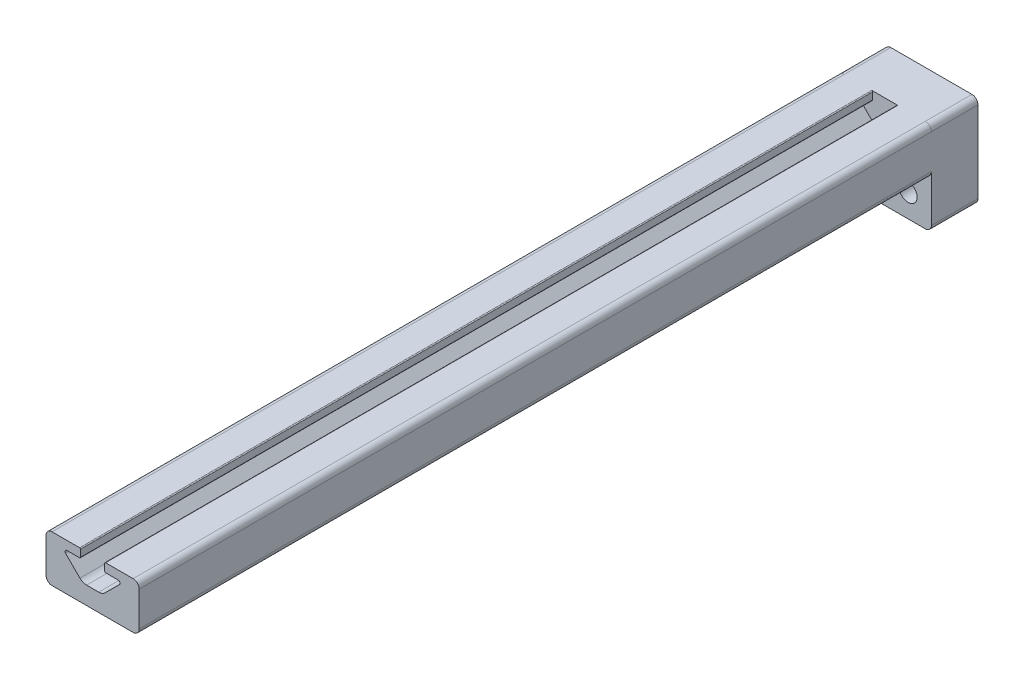
from build123d import *

# Parameters (mm, degrees)
BOSS_EXTRUDE1_DEPTH              = 215.9
FILLET1_R                        = 0.254
SKETCH4_W                        = 25.4
SKETCH4_H                        = 25.4
BOSS_EXTRUDE2_DEPTH              = 12.7
FILLET2_R                        = 1.651
F_10_0_1935_DIAMETER_HOLE1_D     = 4.9149
F_10_0_1935_DIAMETER_HOLE1_DEPTH = 23.923415072
F_10_0_1935_DIAMETER_HOLE1_TIP   = 1.476584928


with BuildPart() as part:
    # Sketch3 → Boss-Extrude1 (new body)
    with BuildSketch(Plane.XY):
        with BuildLine():
            Line((-11.049, 12.7), (-3.302, 12.7))
            Line((-3.302, 12.7), (-3.302, 10.328863887))
            Line((-3.302, 10.328863887), (-6.985, 10.328863887))
            ThreePointArc((-6.985, 10.328863887), (-7.454330803, 10.01526707), (-7.344210245, 9.461653642))
            Line((-7.344210245, 9.461653642), (-3.452505379, 5.569948776))
            ThreePointArc((-3.452505379, 5.569948776), (-2.628470073, 5.019345987), (-1.656454155, 4.826))
            Line((-1.656454155, 4.826), (1.656454155, 4.826))
            ThreePointArc((1.656454155, 4.826), (2.628470073, 5.019345987), (3.452505379, 5.569948776))
            Line((3.452505379, 5.569948776), (7.344210245, 9.461653642))
            ThreePointArc((7.344210245, 9.461653642), (7.454330803, 10.01526707), (6.985, 10.328863887))
            Line((6.985, 10.328863887), (3.302, 10.328863887))
            Line((3.302, 10.328863887), (3.302, 12.7))
            Line((3.302, 12.7), (11.049, 12.7))
            ThreePointArc((11.049, 12.7), (12.216433296, 12.216433296), (12.7, 11.049))
            Line((12.7, 11.049), (12.7, 1.651))
            ThreePointArc((12.7, 1.651), (12.216433296, 0.483566704), (11.049, 0))
            Line((11.049, 0), (-11.049, 0))
            ThreePointArc((-11.049, 0), (-12.216433296, 0.483566704), (-12.7, 1.651))
            Line((-12.7, 1.651), (-12.7, 11.049))
            ThreePointArc((-12.7, 11.049), (-12.216433296, 12.216433296), (-11.049, 12.7))
        make_face()
    extrude(amount=BOSS_EXTRUDE1_DEPTH)

    # Fillet1
    fillet1_edges = [part.edges().sort_by_distance(p)[0] for p in [
        (-3.302, 12.7, 107.95),
        (-3.302, 10.328863887, 107.95),
        (3.302, 10.328863887, 107.95),
        (3.302, 12.7, 107.95),
    ]]
    fillet(fillet1_edges, radius=FILLET1_R)

    # Sketch4 → Boss-Extrude2 (add)
    with BuildSketch(Plane(origin=(0, 0, 0), x_dir=(-1, 0, 0), z_dir=(0, 0, -1))):
        Rectangle(SKETCH4_W, SKETCH4_H)
    extrude(amount=BOSS_EXTRUDE2_DEPTH)

    # Fillet2
    fillet2_edges = [part.edges().sort_by_distance(p)[0] for p in [
        (-12.7, 12.7, -6.35),
        (12.7, 12.7, -6.35),
        (-12.7, -12.7, -6.35),
        (12.7, -12.7, -6.35),
    ]]
    fillet(fillet2_edges, radius=FILLET2_R)

    # #10 (0.1935) Diameter Hole1
    with Locations(Plane(origin=(0, 0, -12.7), x_dir=(-1, 0, 0), z_dir=(0, 0, -1))):
        with Locations((-6.35, -6.35), (6.35, -6.35)):
            Hole(F_10_0_1935_DIAMETER_HOLE1_D / 2, depth=F_10_0_1935_DIAMETER_HOLE1_DEPTH)
            with Locations((0, 0, -(F_10_0_1935_DIAMETER_HOLE1_DEPTH + F_10_0_1935_DIAMETER_HOLE1_TIP / 2))):  # 118° drill point
                Cone(0, F_10_0_1935_DIAMETER_HOLE1_D / 2, F_10_0_1935_DIAMETER_HOLE1_TIP, mode=Mode.SUBTRACT)


solid = part.part
